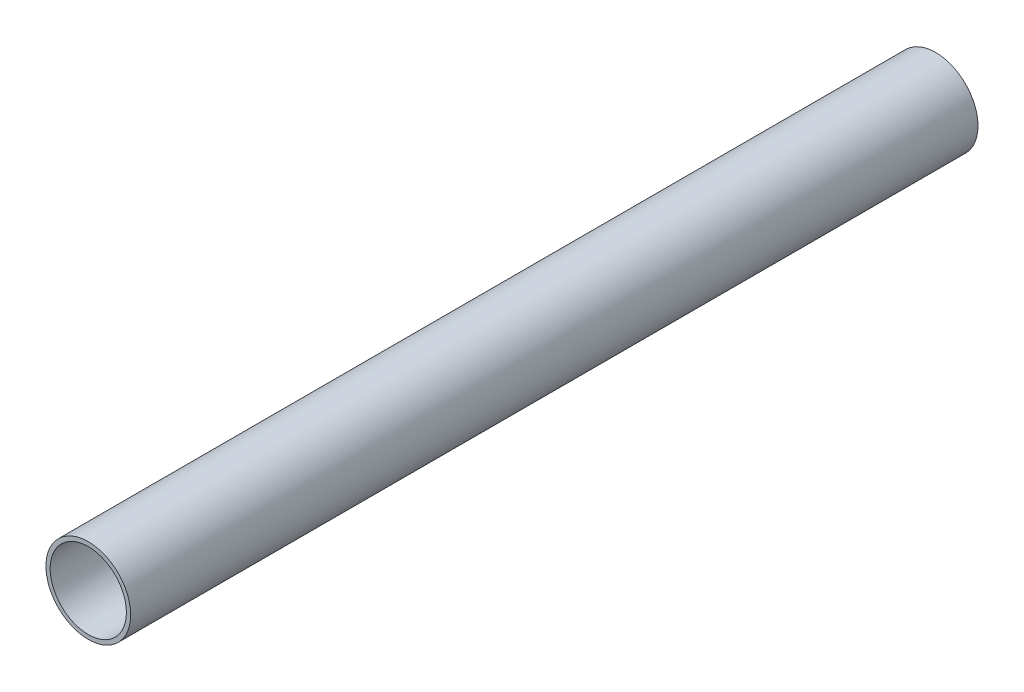
from build123d import *

# Parameters (mm, degrees)
SKETCH3_R           = 10
SKETCH3_R_2         = 9
EXTRUDE_THIN2_DEPTH = 200


with BuildPart() as part:
    # Sketch3 → Extrude-Thin2 (new body)
    with BuildSketch(Plane.XY):
        Circle(SKETCH3_R)
        Circle(SKETCH3_R_2, mode=Mode.SUBTRACT)
    extrude(amount=EXTRUDE_THIN2_DEPTH)


solid = part.part
